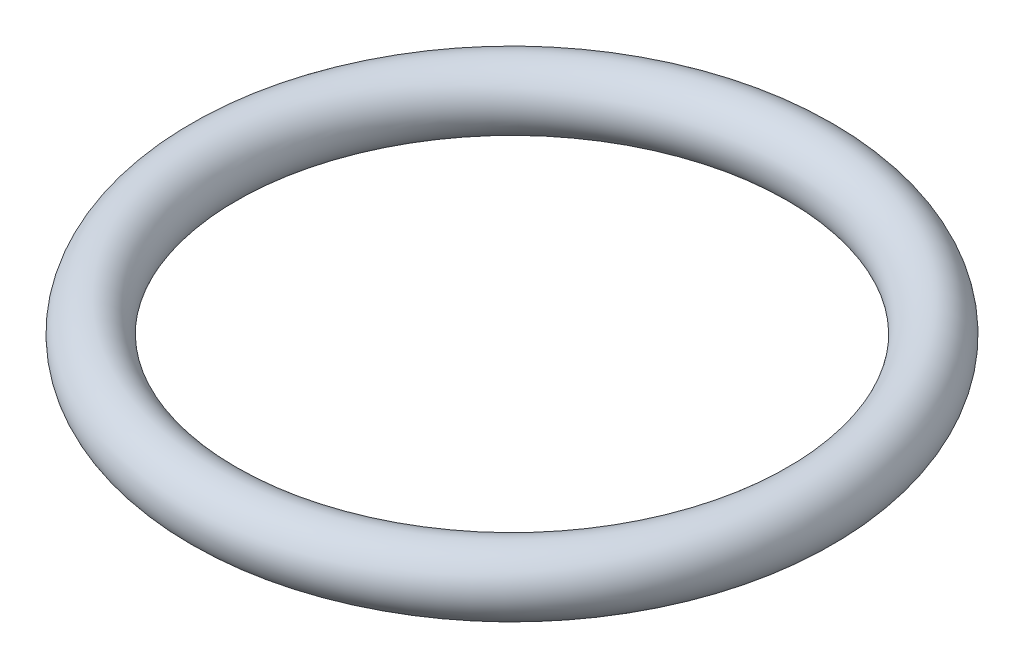
from build123d import *

# Parameters (mm, degrees)
SKETCH_1_R = 0.7


with BuildPart() as part:
    # Эскиз1 → Повернуть1 (revolve)
    with BuildSketch(Plane.XY):
        with Locations((-6.6, 0)):
            Circle(SKETCH_1_R)
    revolve(axis=Axis((0, 0.825, 0), (0, -1, 0)))


solid = part.part
